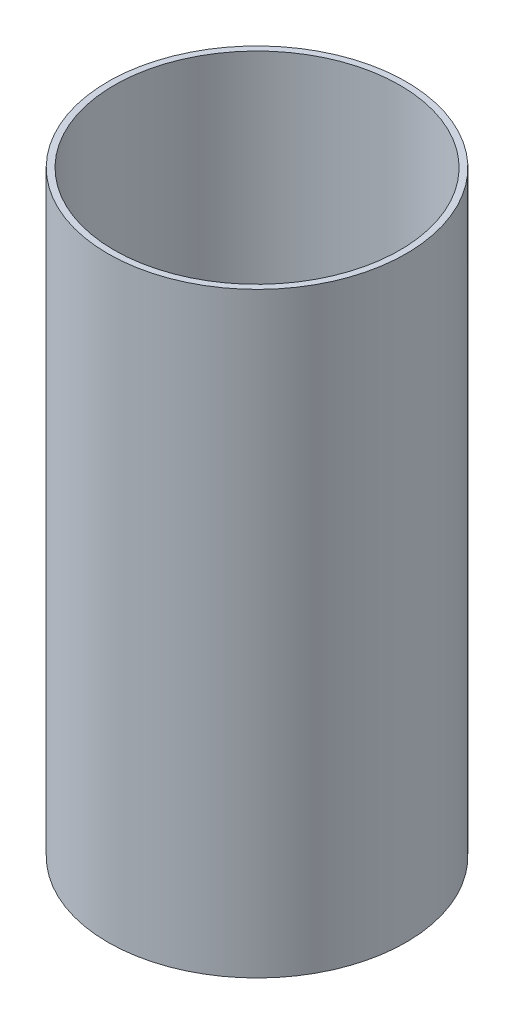
from build123d import *

# Parameters (mm, degrees)
SKETCH1_R           = 76.2
SKETCH1_R_2         = 73.025
BOSS_EXTRUDE1_DEPTH = 304.8


with BuildPart() as part:
    # Sketch1 → Boss-Extrude1 (new body)
    with BuildSketch(Plane(origin=(0, 0, 0), x_dir=(1, 0, 0), z_dir=(0, 1, 0))):
        Circle(SKETCH1_R)
        Circle(SKETCH1_R_2, mode=Mode.SUBTRACT)
    extrude(amount=BOSS_EXTRUDE1_DEPTH)


solid = part.part
